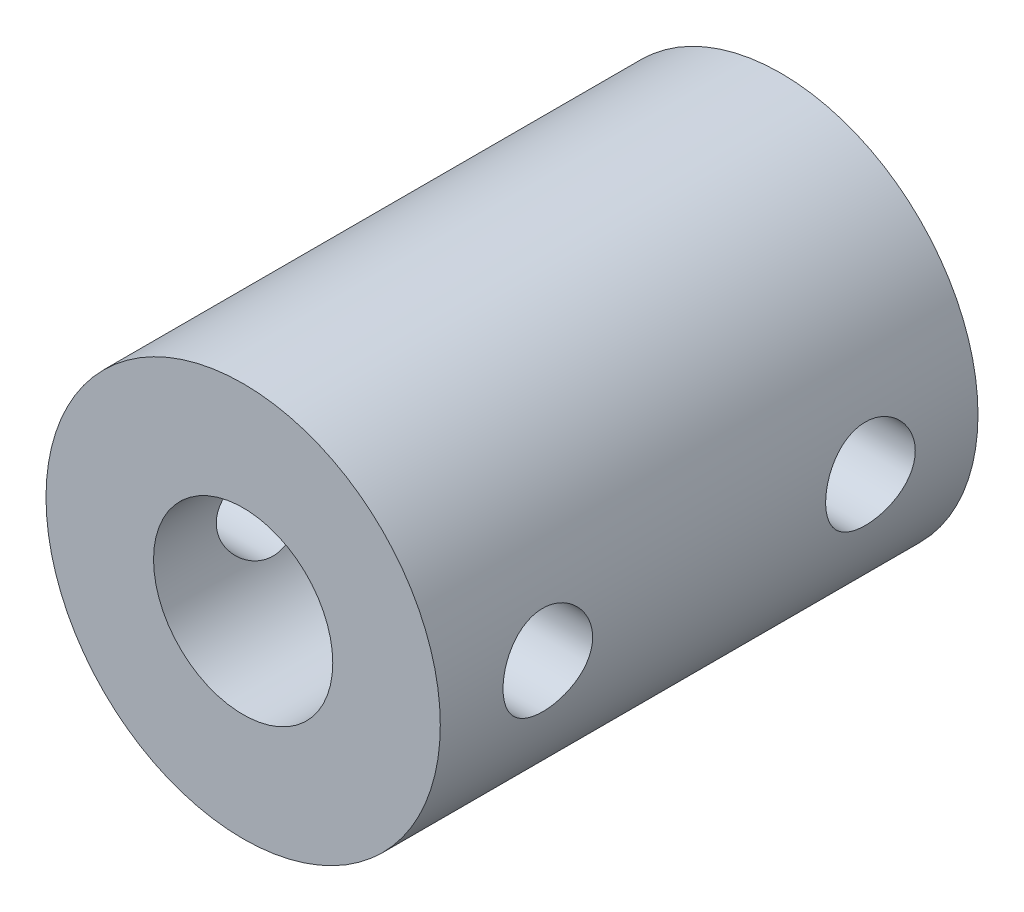
from build123d import *

# Parameters (mm, degrees)
SKETCH_1_R        = 5.5
SKETCH_1_R_2      = 2.5
EXTRUDE_1_DEPTH   = 15
HOLE_WIZARD_M31_D = 2.5


with BuildPart() as part:
    # Эскиз1 → Бобышка-Вытянуть1 (new body)
    with BuildSketch(Plane.XY):
        Circle(SKETCH_1_R)
        Circle(SKETCH_1_R_2, mode=Mode.SUBTRACT)
    extrude(amount=EXTRUDE_1_DEPTH)

    # Отверстие обработанное метчиком M31 (through all)
    with Locations(Plane.ZY.offset(5.5)):
        with Locations((12, 0), (3, 0)):
            Hole(HOLE_WIZARD_M31_D / 2)


solid = part.part
